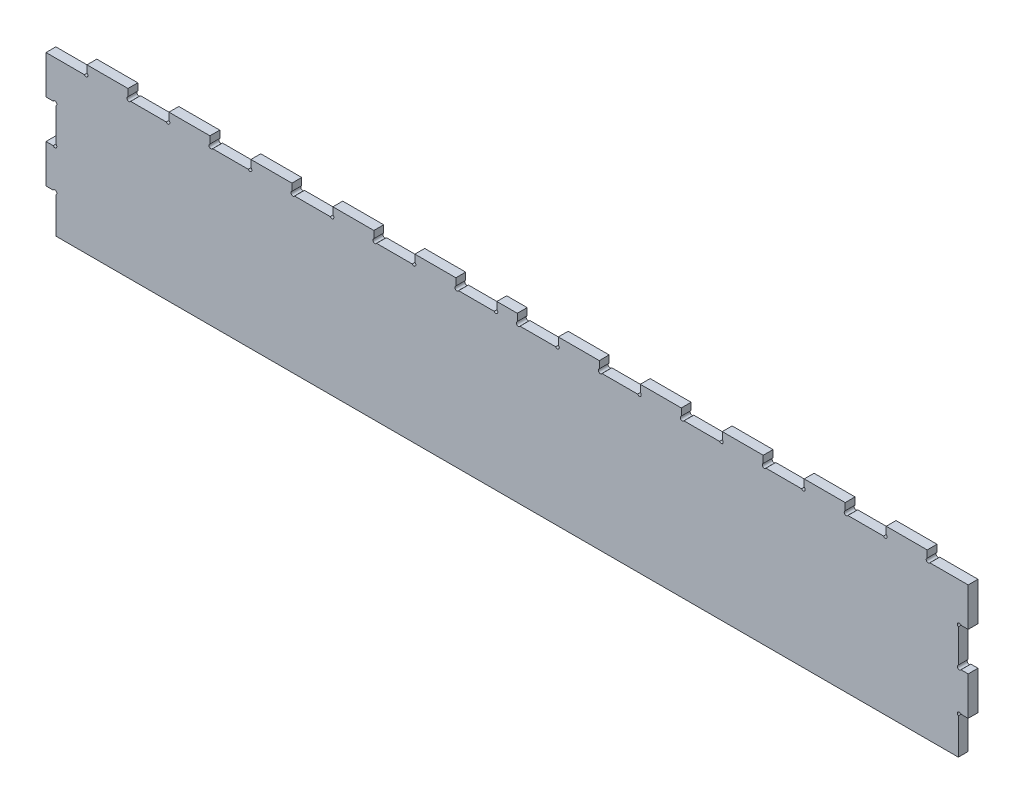
from build123d import *

# Parameters (mm, degrees)
BOSS_EXTRUDE1_DEPTH = 12


with BuildPart() as part:
    # Sketch1 → Boss-Extrude1 (new body)
    with BuildSketch(Plane.XY):
        with BuildLine():
            Line((-398.481522137, 104.896883683), (-351.779111417, 104.896883683))
            ThreePointArc((-351.779111417, 104.896883683), (-348.011442278, 104.39201543), (-348.481522137, 108.164182926))
            Line((-348.481522137, 108.164182926), (-348.481522137, 116.896883683))
            Line((-348.481522137, 116.896883683), (-298.481522137, 116.896883683))
            Line((-298.481522137, 116.896883683), (-298.481522137, 108.164182926))
            ThreePointArc((-298.481522137, 108.164182926), (-298.951601996, 104.39201543), (-295.183932857, 104.896883683))
            Line((-295.183932857, 104.896883683), (-251.779111417, 104.896883683))
            ThreePointArc((-251.779111417, 104.896883683), (-248.011442278, 104.39201543), (-248.481522137, 108.164182926))
            Line((-248.481522137, 108.164182926), (-248.481522137, 116.896883683))
            Line((-248.481522137, 116.896883683), (-198.481522137, 116.896883683))
            Line((-198.481522137, 116.896883683), (-198.481522137, 108.164182926))
            ThreePointArc((-198.481522137, 108.164182926), (-198.951601996, 104.39201543), (-195.183932857, 104.896883683))
            Line((-195.183932857, 104.896883683), (-151.779111417, 104.896883683))
            ThreePointArc((-151.779111417, 104.896883683), (-148.011442278, 104.39201543), (-148.481522137, 108.164182926))
            Line((-148.481522137, 108.164182926), (-148.481522137, 116.896883683))
            Line((-148.481522137, 116.896883683), (-98.481522137, 116.896883683))
            Line((-98.481522137, 116.896883683), (-98.481522137, 108.164182926))
            ThreePointArc((-98.481522137, 108.164182926), (-98.951601996, 104.39201543), (-95.183932857, 104.896883683))
            Line((-95.183932857, 104.896883683), (-51.779111417, 104.896883683))
            ThreePointArc((-51.779111417, 104.896883683), (-48.011442278, 104.39201543), (-48.481522137, 108.164182926))
            Line((-48.481522137, 108.164182926), (-48.481522137, 116.896883683))
            Line((-48.481522137, 116.896883683), (1.518477863, 116.896883683))
            Line((1.518477863, 116.896883683), (1.518477863, 108.164182926))
            ThreePointArc((1.518477863, 108.164182926), (1.048398004, 104.39201543), (4.816067143, 104.896883683))
            Line((4.816067143, 104.896883683), (48.220888583, 104.896883683))
            ThreePointArc((48.220888583, 104.896883683), (51.988557722, 104.39201543), (51.518477863, 108.164182926))
            Line((51.518477863, 108.164182926), (51.518477863, 116.896883683))
            Line((51.518477863, 116.896883683), (101.518477863, 116.896883683))
            Line((101.518477863, 116.896883683), (101.518477863, 108.164182926))
            ThreePointArc((101.518477863, 108.164182926), (101.048398004, 104.39201543), (104.816067143, 104.896883683))
            Line((104.816067143, 104.896883683), (148.220888583, 104.896883683))
            ThreePointArc((148.220888583, 104.896883683), (151.988557722, 104.39201543), (151.518477863, 108.164182926))
            Line((151.518477863, 108.164182926), (151.518477863, 116.896883683))
            Line((151.518477863, 116.896883683), (176.518477863, 116.896883683))
            Line((176.518477863, 116.896883683), (176.518477863, 108.164182926))
            ThreePointArc((176.518477863, 108.164182926), (176.048398004, 104.39201543), (179.816067143, 104.896883683))
            Line((179.816067143, 104.896883683), (223.220888583, 104.896883683))
            ThreePointArc((223.220888583, 104.896883683), (226.988557722, 104.39201543), (226.518477863, 108.164182926))
            Line((226.518477863, 108.164182926), (226.518477863, 116.896883683))
            Line((226.518477863, 116.896883683), (276.518477863, 116.896883683))
            Line((276.518477863, 116.896883683), (276.518477863, 108.164182926))
            ThreePointArc((276.518477863, 108.164182926), (276.048398004, 104.39201543), (279.816067143, 104.896883683))
            Line((279.816067143, 104.896883683), (323.220888583, 104.896883683))
            ThreePointArc((323.220888583, 104.896883683), (326.988557722, 104.39201543), (326.518477863, 108.164182926))
            Line((326.518477863, 108.164182926), (326.518477863, 116.896883683))
            Line((326.518477863, 116.896883683), (376.518477863, 116.896883683))
            Line((376.518477863, 116.896883683), (376.518477863, 108.164182926))
            ThreePointArc((376.518477863, 108.164182926), (376.048398004, 104.39201543), (379.816067143, 104.896883683))
            Line((379.816067143, 104.896883683), (423.220888583, 104.896883683))
            ThreePointArc((423.220888583, 104.896883683), (426.988557722, 104.39201543), (426.518477863, 108.164182926))
            Line((426.518477863, 108.164182926), (426.518477863, 116.896883683))
            Line((426.518477863, 116.896883683), (476.518477863, 116.896883683))
            Line((476.518477863, 116.896883683), (476.518477863, 108.164182926))
            ThreePointArc((476.518477863, 108.164182926), (476.048398004, 104.39201543), (479.816067143, 104.896883683))
            Line((479.816067143, 104.896883683), (523.220888583, 104.896883683))
            ThreePointArc((523.220888583, 104.896883683), (526.988557722, 104.39201543), (526.518477863, 108.164182926))
            Line((526.518477863, 108.164182926), (526.518477863, 116.896883683))
            Line((526.518477863, 116.896883683), (576.518477863, 116.896883683))
            Line((576.518477863, 116.896883683), (576.518477863, 108.164182926))
            ThreePointArc((576.518477863, 108.164182926), (576.048398004, 104.39201543), (579.816067143, 104.896883683))
            Line((579.816067143, 104.896883683), (623.220888583, 104.896883683))
            ThreePointArc((623.220888583, 104.896883683), (626.988557722, 104.39201543), (626.518477863, 108.164182926))
            Line((626.518477863, 108.164182926), (626.518477863, 116.896883683))
            Line((626.518477863, 116.896883683), (676.518477863, 116.896883683))
            Line((676.518477863, 116.896883683), (676.518477863, 108.164182926))
            ThreePointArc((676.518477863, 108.164182926), (676.048398004, 104.39201543), (679.816067143, 104.896883683))
            Line((679.816067143, 104.896883683), (726.518477863, 104.896883683))
            Line((726.518477863, 104.896883683), (726.518477863, 57.896883683))
            Line((726.518477863, 57.896883683), (717.793597981, 57.896883683))
            ThreePointArc((717.793597981, 57.896883683), (714.01671802, 58.392576145), (714.518477863, 54.616497449))
            Line((714.518477863, 54.616497449), (714.518477863, 14.177269917))
            ThreePointArc((714.518477863, 14.177269917), (714.01671802, 10.401191221), (717.793597981, 10.896883683))
            Line((717.793597981, 10.896883683), (726.518477863, 10.896883683))
            Line((726.518477863, 10.896883683), (726.518477863, -36.103116317))
            Line((726.518477863, -36.103116317), (717.793597981, -36.103116317))
            ThreePointArc((717.793597981, -36.103116317), (714.01671802, -35.607423855), (714.518477863, -39.383502551))
            Line((714.518477863, -39.383502551), (714.518477863, -71.103116317))
            Line((714.518477863, -71.103116317), (714.518477863, -83.103116317))
            Line((714.518477863, -83.103116317), (-386.481522137, -83.103116317))
            Line((-386.481522137, -83.103116317), (-386.481522137, -39.383502551))
            ThreePointArc((-386.481522137, -39.383502551), (-385.979762293, -35.607423855), (-389.756642255, -36.103116317))
            Line((-389.756642255, -36.103116317), (-398.481522137, -36.103116317))
            Line((-398.481522137, -36.103116317), (-398.481522137, 10.896883683))
            Line((-398.481522137, 10.896883683), (-389.756642255, 10.896883683))
            ThreePointArc((-389.756642255, 10.896883683), (-385.979762293, 10.401191221), (-386.481522137, 14.177269917))
            Line((-386.481522137, 14.177269917), (-386.481522137, 54.616497449))
            ThreePointArc((-386.481522137, 54.616497449), (-385.979762293, 58.392576145), (-389.756642255, 57.896883683))
            Line((-389.756642255, 57.896883683), (-398.481522137, 57.896883683))
            Line((-398.481522137, 57.896883683), (-398.481522137, 104.896883683))
        make_face()
    extrude(amount=BOSS_EXTRUDE1_DEPTH)


solid = part.part
